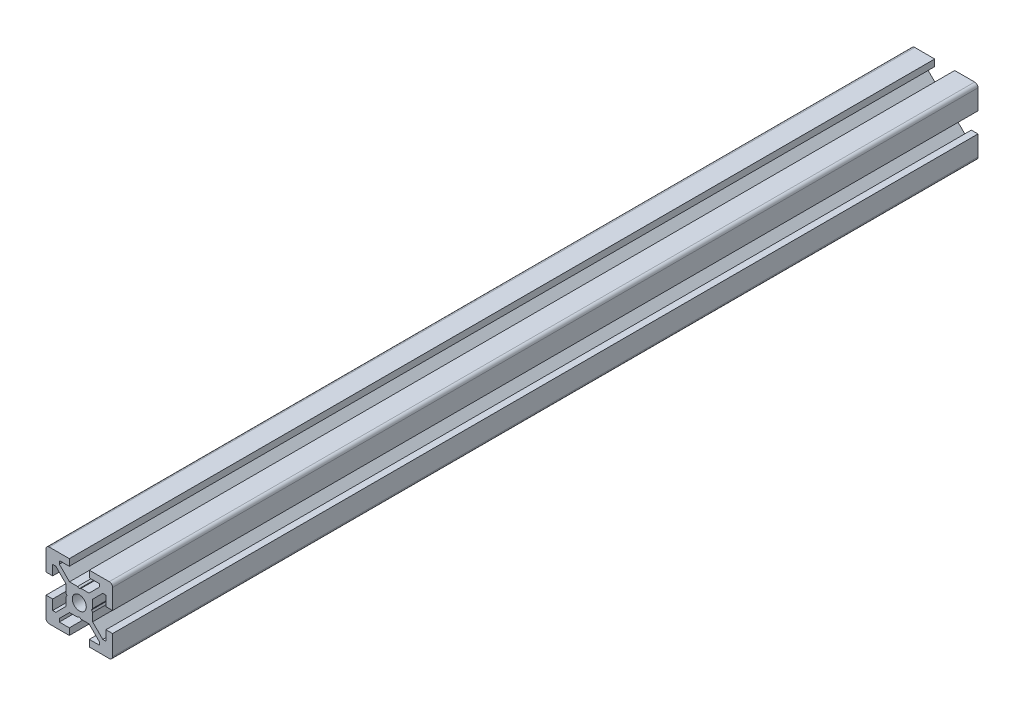
from build123d import *

# Parameters (mm, degrees)
EXTRUDE_1_DEPTH = 260
SKETCH_2_W      = 260
SKETCH_2_H      = 2.1


with BuildPart() as part:
    # ｽｹｯﾁ1 → ﾎﾞｽ - 押し出し1 (new body)
    with BuildSketch(Plane.XY):
        with BuildLine():
            Line((-10, -3), (-10, -9))
            ThreePointArc((-10, -9), (-9.707106781, -9.707106781), (-9, -10))
            Line((-9, -10), (-3, -10))
            Line((-3, -10), (-3, -8))
            Line((-3, -8), (-6, -8))
            Line((-6, -8), (-6, -7.060660172))
            Line((-6, -7.060660172), (-2.939339828, -4))
            Line((-2.939339828, -4), (-0.519615242, -4))
            Line((-0.519615242, -4), (0, -3.7))
            Line((0, -3.7), (0.519615242, -4))
            Line((0.519615242, -4), (2.939339828, -4))
            Line((2.939339828, -4), (6, -7.060660172))
            Line((6, -7.060660172), (6, -8))
            Line((6, -8), (3, -8))
            Line((3, -8), (3, -10))
            Line((3, -10), (9, -10))
            ThreePointArc((9, -10), (9.707106781, -9.707106781), (10, -9))
            Line((10, -9), (10, -3))
            Line((10, -3), (8, -3))
            Line((8, -3), (8, -6))
            Line((8, -6), (7.060660172, -6))
            Line((7.060660172, -6), (4, -2.939339828))
            Line((4, -2.939339828), (4, -0.519615242))
            Line((4, -0.519615242), (3.7, 0))
            Line((3.7, 0), (4, 0.519615242))
            Line((4, 0.519615242), (4, 2.939339828))
            Line((4, 2.939339828), (7.060660172, 6))
            Line((7.060660172, 6), (8, 6))
            Line((8, 6), (8, 3))
            Line((8, 3), (10, 3))
            Line((10, 3), (10, 9))
            ThreePointArc((10, 9), (9.707106781, 9.707106781), (9, 10))
            Line((9, 10), (3, 10))
            Line((3, 10), (3, 8))
            Line((3, 8), (6, 8))
            Line((6, 8), (6, 7.060660172))
            Line((6, 7.060660172), (2.939339828, 4))
            Line((2.939339828, 4), (0.519615242, 4))
            Line((0.519615242, 4), (0, 3.7))
            Line((0, 3.7), (-0.519615242, 4))
            Line((-0.519615242, 4), (-2.939339828, 4))
            Line((-2.939339828, 4), (-6, 7.060660172))
            Line((-6, 7.060660172), (-6, 8))
            Line((-6, 8), (-3, 8))
            Line((-3, 8), (-3, 10))
            Line((-3, 10), (-9, 10))
            ThreePointArc((-9, 10), (-9.707106781, 9.707106781), (-10, 9))
            Line((-10, 9), (-10, 3))
            Line((-10, 3), (-8, 3))
            Line((-8, 3), (-8, 6))
            Line((-8, 6), (-7.060660172, 6))
            Line((-7.060660172, 6), (-4, 2.939339828))
            Line((-4, 2.939339828), (-4, 0.519615242))
            Line((-4, 0.519615242), (-3.7, 0))
            Line((-3.7, 0), (-4, -0.519615242))
            Line((-4, -0.519615242), (-4, -2.939339828))
            Line((-4, -2.939339828), (-7.060660172, -6))
            Line((-7.060660172, -6), (-8, -6))
            Line((-8, -6), (-8, -3))
            Line((-8, -3), (-10, -3))
        make_face()
    extrude(amount=-EXTRUDE_1_DEPTH)

    # ｽｹｯﾁ2 → ｶｯﾄ - 回転1 (revolve, cut)
    with BuildSketch(Plane(origin=(0, 0, 0), x_dir=(0, 0, -1), z_dir=(1, 0, 0))):
        with Locations((130, 1.05)):
            Rectangle(SKETCH_2_W, SKETCH_2_H)
    revolve(axis=Axis((0, 0, -260), (0, 0, 1)), mode=Mode.SUBTRACT)


solid = part.part
